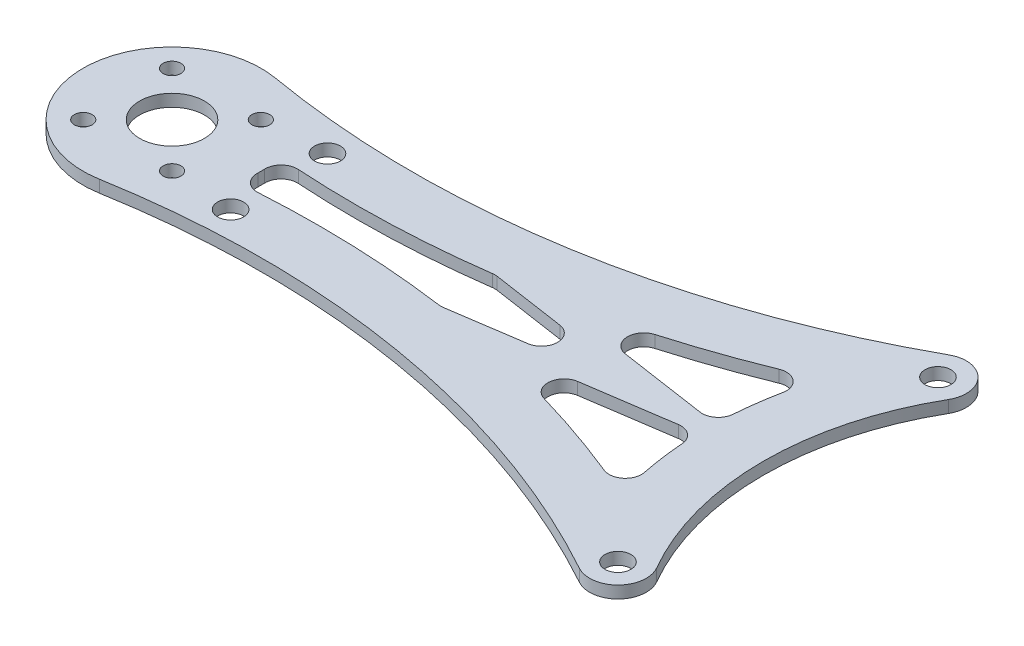
from build123d import *

# Parameters (mm, degrees)
SKETCH1_R                      = 3.5
BOSS_EXTRUDE1_DEPTH            = 0.75
F_2_2_2_2_DIAMETER_HOLE1_D     = 2.2
F_3_2_3_2_DIAMETER_HOLE1_D     = 3.2
F_3_2_3_2_DIAMETER_HOLE1_DEPTH = 10
F_3_2_3_2_DIAMETER_HOLE1_TIP   = 0.96137699
CUT_EXTRUDE1_DEPTH             = 2.5
FILLET1_R                      = 2
SKETCH7_R                      = 4
CUT_EXTRUDE2_DEPTH             = 2.5000001


with BuildPart() as part:
    # Sketch1 → Boss-Extrude1 (new body, symmetric)
    with BuildSketch(Plane(origin=(0, 0, 0), x_dir=(1, 0, 0), z_dir=(0, 1, 0))):
        with BuildLine():
            ThreePointArc((-37.239092363, -21.5), (-43, 0), (-37.239092363, 21.5))
            ThreePointArc((-37.239092363, 21.5), (-36.658838331, 22.248681329), (-35.899079455, 22.81435343))
            ThreePointArc((-35.899079455, 22.81435343), (-70.492179883, 10.7556392), (-107.126701642, 10.839315166))
            ThreePointArc((-107.126701642, 10.839315166), (-120, 0), (-107.126701642, -10.839315166))
            ThreePointArc((-107.126701642, -10.839315166), (-70.492179883, -10.7556392), (-35.899079455, -22.81435343))
            ThreePointArc((-35.899079455, -22.81435343), (-36.658838331, -22.248681329), (-37.239092363, -21.5))
        make_face()
        with BuildLine():
            ThreePointArc((-31.176914536, 18), (-35.958003449, 16.718911087), (-37.239092363, 21.5))
            ThreePointArc((-37.239092363, 21.5), (-43, 0), (-37.239092363, -21.5))
            ThreePointArc((-37.239092363, -21.5), (-35.958003449, -16.718911087), (-31.176914536, -18))
            ThreePointArc((-31.176914536, -18), (-36, 0), (-31.176914536, 18))
        make_face()
        with Locations((-34.208003449, -19.75)):
            Circle(SKETCH1_R)
        with Locations((-34.208003449, 19.75)):
            Circle(SKETCH1_R)
    extrude(amount=BOSS_EXTRUDE1_DEPTH, both=True)

    # Ø2.2 (2.2) Diameter Hole1 (through all)
    with Locations(Plane(origin=(0, 0.75, 0), x_dir=(1, 0, 0), z_dir=(0, 1, 0))):
        with Locations((-114.480077554, 5.480077554), (-103.519922446, 5.480077554), (-103.519922446, -5.480077554), (-114.480077554, -5.480077554)):
            Hole(F_2_2_2_2_DIAMETER_HOLE1_D / 2)

    # Ø3.2 (3.2) Diameter Hole1
    with Locations(Plane(origin=(0, 0.75, 0), x_dir=(1, 0, 0), z_dir=(0, 1, 0))):
        with Locations((-34.208003449, 19.75), (-34.208003449, -19.75), (-95.790276336, 5.979398024), (-95.790276336, -5.979398024)):
            Hole(F_3_2_3_2_DIAMETER_HOLE1_D / 2, depth=F_3_2_3_2_DIAMETER_HOLE1_DEPTH)
            with Locations((0, 0, -(F_3_2_3_2_DIAMETER_HOLE1_DEPTH + F_3_2_3_2_DIAMETER_HOLE1_TIP / 2))):  # 118° drill point
                Cone(0, F_3_2_3_2_DIAMETER_HOLE1_D / 2, F_3_2_3_2_DIAMETER_HOLE1_TIP, mode=Mode.SUBTRACT)

    # Sketch6 → Cut-Extrude1 (cut, through all)
    with BuildSketch(Plane(origin=(0, 0.75, 0), x_dir=(1, 0, 0), z_dir=(0, 1, 0))):
        with BuildLine():
            Line((-72.469338063, -3.369046694), (-49.802019621, 0))
            Line((-49.802019621, 0), (-72.469338063, 3.369046694))
            ThreePointArc((-72.469338063, 3.369046694), (-85.377857375, 2.290839769), (-98.326107181, 2.65857332))
            ThreePointArc((-98.326107181, 2.65857332), (-98, 0), (-98.326107181, -2.65857332))
            ThreePointArc((-98.326107181, -2.65857332), (-85.377857375, -2.290839769), (-72.469338063, -3.369046694))
        make_face()
        with BuildLine():
            Line((-66.096117167, 4.443764231), (-42.988154947, 1.009224591))
            ThreePointArc((-42.988154947, 1.009224591), (-42.467311238, 6.747405149), (-41.183985346, 12.36443897))
            ThreePointArc((-41.183985346, 12.36443897), (-53.416219701, 7.70010587), (-66.096117167, 4.443764231))
        make_face()
        with BuildLine():
            ThreePointArc((-41.183985346, -12.36443897), (-42.467311238, -6.747405149), (-42.988154947, -1.009224591))
            Line((-42.988154947, -1.009224591), (-66.096117167, -4.443764231))
            ThreePointArc((-66.096117167, -4.443764231), (-53.416219701, -7.70010587), (-41.183985346, -12.36443897))
        make_face()
    extrude(amount=-CUT_EXTRUDE1_DEPTH, mode=Mode.SUBTRACT)

    # Fillet1
    fillet1_edges = [part.edges().sort_by_distance(p)[0] for p in [
        (-42.988154947, 0, 1.009224591),
        (-41.183985346, 0, 12.36443897),
        (-66.096117167, 0, 4.443764231),
        (-98.326107181, 0, 2.65857332),
        (-98.326107181, 0, -2.65857332),
        (-72.469338063, 0, -3.369046694),
        (-49.802019621, 0, 0),
        (-72.469338063, 0, 3.369046694),
        (-41.183985346, 0, -12.36443897),
        (-42.988154947, 0, -1.009224591),
        (-66.096117167, 0, -4.443764231),
    ]]
    fillet(fillet1_edges, radius=FILLET1_R)

    # Sketch7 → Cut-Extrude2 (cut, through all)
    with BuildSketch(Plane(origin=(0, 0.75, 0), x_dir=(1, 0, 0), z_dir=(0, 1, 0))):
        with Locations((-109, 0)):
            Circle(SKETCH7_R)
    extrude(amount=-CUT_EXTRUDE2_DEPTH, mode=Mode.SUBTRACT)


solid = part.part
